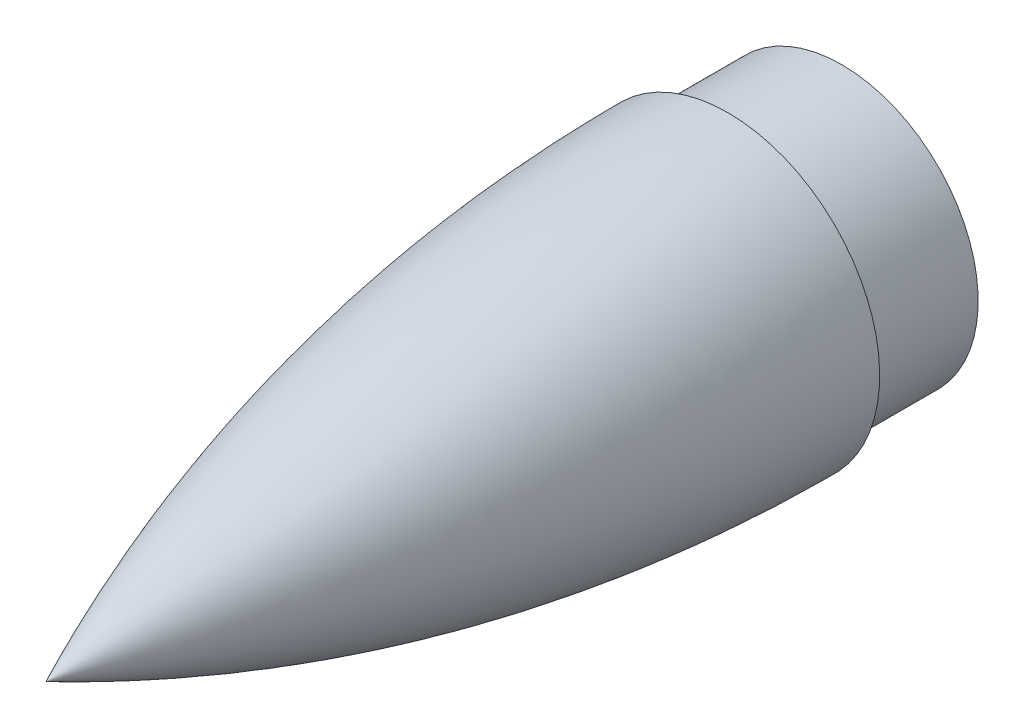
from build123d import *


with BuildPart() as part:
    # Sketch2 → Revolve1 (revolve)
    with BuildSketch(Plane(origin=(0, 0, 0), x_dir=(0, 0, -1), z_dir=(1, 0, 0))):
        with BuildLine():
            Line((90, 20.000000007), (90, 18))
            Line((90, 18), (104.999999999, 18))
            Line((104.999999999, 18), (104.999999999, 0))
            Line((104.999999999, 0), (-1e-09, 0))
            add(Edge.make_bspline(
                [(-1e-09, 0), (9.999999999, 4.675323888), (19.999999999, 8.638491903), (29.999999999, 11.956195858), (39.999999999, 14.671947003), (49.999999999, 16.816757529), (60, 18.411759116), (70, 19.470590362), (80, 19.999999507), (90, 20.000000007)],
                knots=[0.077399556, 0.077399556, 0.077399556, 0.077399556, 0.077399556, 0.077399556, 0.077399556, 0.077399556, 0.077399556, 0.077399556, 0.916127232, 0.916127232, 0.916127232, 0.916127232, 0.916127232, 0.916127232, 0.916127232, 0.916127232, 0.916127232, 0.916127232], degree=9))
        make_face()
    revolve(axis=Axis((0, 0, -104.999999999), (0, 0, 1)))


solid = part.part
